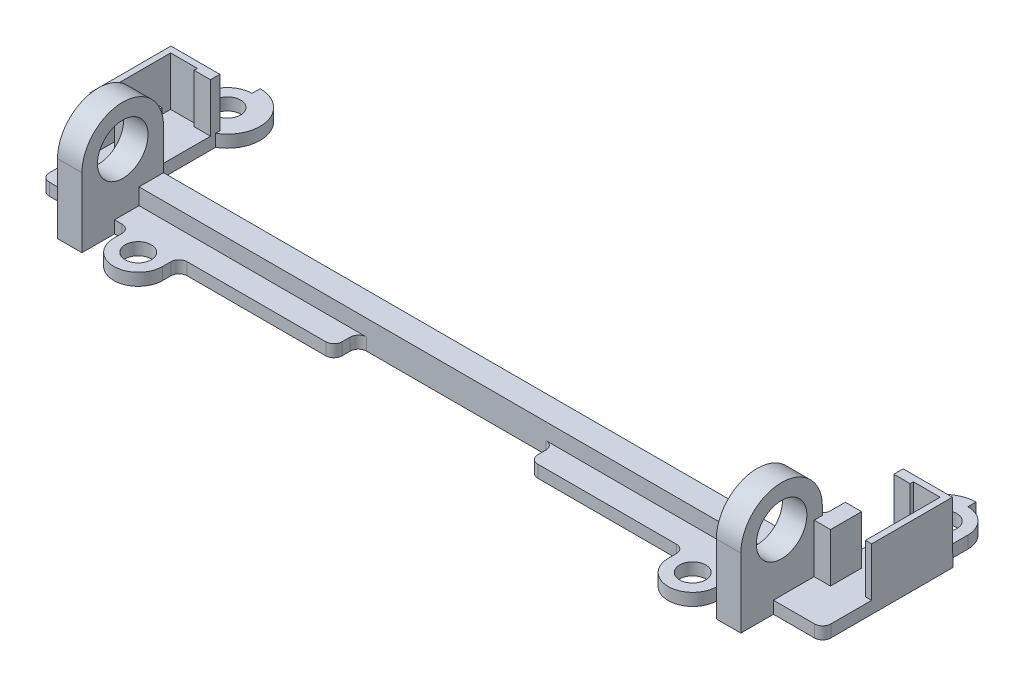
from build123d import *

# Parameters (mm, degrees)
BOSS_EXTRUDE1_START      = -0.5
BOSS_EXTRUDE1_DEPTH      = 1.5
SKETCH2_R                = 1.6
CUT_EXTRUDE1_DEPTH       = 1
SKETCH3_W                = 0.75
SKETCH3_H                = 10
BOSS_EXTRUDE2_DEPTH      = 5
BOSS_EXTRUDE3_DEPTH      = 5
SKETCH5_W                = 4.286948095
SKETCH5_H                = 10
SKETCH5_W_2              = 4.25
CUT_EXTRUDE2_DEPTH       = 51
SKETCH6_R                = 1.6
BOSS_EXTRUDE4_DEPTH      = 1.5
CUT_EXTRUDE3_DEPTH       = 51
SKETCH9_W                = 1.486095819
SKETCH9_H                = 8.860387047
BOSS_EXTRUDE5_DEPTH      = 1.5
SKETCH10_W               = 0.325570639
SKETCH10_H               = 19.562658846
CUT_EXTRUDE4_DEPTH       = 51
SKETCH11_W               = 2.963051905
SKETCH11_H               = 0.75
BOSS_EXTRUDE6_DEPTH      = 5
CUT_EXTRUDE5_DEPTH       = 24
CUT_EXTRUDE5_DEPTH_BACK  = 10
SKETCH13_W               = 3.75
SKETCH13_H               = 0.877509659
BOSS_EXTRUDE7_DEPTH      = 5
CUT_EXTRUDE8_DEPTH       = 24
CUT_EXTRUDE9_DEPTH       = 24
SKETCH17_W               = 0.75
SKETCH17_H               = 6
CUT_EXTRUDE10_DEPTH      = 5
SKETCH18_R               = 23.563535961
CUT_EXTRUDE11_DEPTH      = 50
SKETCH19_W               = 0.75
SKETCH19_H               = 3.122490341
SKETCH19_W_2             = 3.75
SKETCH19_H_2             = 0.877509659
BOSS_EXTRUDE8_DEPTH      = 5
BOSS_EXTRUDE9_DEPTH      = 1.5
SKETCH21_R               = 54.234395916
CUT_EXTRUDE12_DEPTH      = 26
BOSS_EXTRUDE10_DEPTH     = 1.5
BOSS_EXTRUDE11_DEPTH     = 1.5
SKETCH24_W               = 6.036948095
SKETCH24_H               = 1
SKETCH24_W_2             = 6
SKETCH24_W_3             = 2
SKETCH24_H_2             = 2.410061644
BOSS_EXTRUDE13_DEPTH     = 6
SKETCH25_W               = 2.5
SKETCH25_H               = 0.4
BOSS_EXTRUDE14_DEPTH     = 6
SKETCH26_W               = 0.75
SKETCH26_H               = 8.410061644
BOSS_EXTRUDE15_DEPTH     = 6
SKETCH27_W               = 0.5
SKETCH27_H               = 8.410061644
CUT_EXTRUDE13_DEPTH      = 6
SKETCH28_W               = 3
SKETCH28_H               = 4
BOSS_EXTRUDE18_DEPTH     = 13
SKETCH29_R               = 3.1
CUT_EXTRUDE14_DEPTH      = 154
CUT_EXTRUDE14_DEPTH_BACK = 13
SKETCH30_W               = 2
SKETCH30_H               = 5.827825404
CUT_EXTRUDE15_DEPTH      = 20
SKETCH31_W               = 8
SKETCH31_H               = 3
CUT_EXTRUDE16_DEPTH      = 20
SKETCH32_R               = 1.6
BOSS_EXTRUDE19_DEPTH     = 1.5
SKETCH34_W               = 3
SKETCH34_H               = 4
BOSS_EXTRUDE20_DEPTH     = 1.5
SKETCH35_W               = 4
SKETCH35_H               = 3
CUT_EXTRUDE17_DEPTH      = 1.5
FILLET2_R                = 1
BOSS_EXTRUDE21_DEPTH     = 2
SKETCH37_W               = 6
SKETCH37_H               = 0.5
BOSS_EXTRUDE22_DEPTH     = 6
SKETCH38_W               = 0.036948095
SKETCH38_H               = 0.5
BOSS_EXTRUDE23_DEPTH     = 6
SKETCH39_W               = 0.036948095
SKETCH39_H               = 8.410061644
CUT_EXTRUDE18_DEPTH      = 14
CUT_EXTRUDE19_DEPTH      = 6
SKETCH41_W               = 2
SKETCH41_H               = 0.4
BOSS_EXTRUDE25_DEPTH     = 6
CUT_EXTRUDE20_DEPTH      = 6
SKETCH43_W               = 2
SKETCH43_H               = 0.4
BOSS_EXTRUDE26_DEPTH     = 6
SKETCH44_R               = 3.1
BOSS_EXTRUDE27_DEPTH     = 3
SKETCH45_R               = 1.6
CUT_EXTRUDE21_DEPTH      = 8
CUT_EXTRUDE21_DEPTH_BACK = 155
SKETCH46_R               = 3.1
BOSS_EXTRUDE28_DEPTH     = 3
SKETCH47_R               = 3.1
CUT_EXTRUDE22_DEPTH      = 155
SKETCH49_R               = 4
BOSS_EXTRUDE29_DEPTH     = 1.5
SKETCH50_R               = 1.6
CUT_EXTRUDE23_DEPTH      = 10
CUT_EXTRUDE25_DEPTH      = 3.5


with BuildPart() as part:
    # Sketch1 → Boss-Extrude1 (new body)
    with BuildSketch(Plane(origin=(0, 0, 0), x_dir=(1, 0, 0), z_dir=(0, 1, 0)).offset(BOSS_EXTRUDE1_START)):
        Polygon((0, 0), (39.901051905, 0), (39.901051905, 10), (43.938, 10), (47.938, 10), (47.938, -6), (-47.938, -6), (-47.938, 10), (-43.938, 10), (-39.938, 10), (-39.938, 0), align=None)
    boss_extrude1 = extrude(amount=BOSS_EXTRUDE1_DEPTH)

    # Sketch2 → Cut-Extrude1 (cut)
    with BuildSketch(Plane(origin=(0, 1, 0), x_dir=(1, 0, 0), z_dir=(0, 1, 0))):
        with Locations(Location((-43.938, 2.852566903, 0), (0, 0, 270))):
            Circle(SKETCH2_R)
        with Locations(Location((43.921766654, 2.513393114, 0), (0, 0, 90))):
            Circle(SKETCH2_R)
    extrude(amount=-CUT_EXTRUDE1_DEPTH, mode=Mode.SUBTRACT)

    # Sketch3 → Boss-Extrude2 (add)
    with BuildSketch(Plane(origin=(0, 1, 0), x_dir=(1, 0, 0), z_dir=(0, 1, 0))):
        with Locations((-40.313, 5)):
            Rectangle(SKETCH3_W, SKETCH3_H)
        with Locations((40.276051905, 5)):
            Rectangle(SKETCH3_W, SKETCH3_H)
    extrude(amount=BOSS_EXTRUDE2_DEPTH)

    # Sketch4 → Boss-Extrude3 (add)
    with BuildSketch(Plane(origin=(0, 1, 0), x_dir=(1, 0, 0), z_dir=(0, 1, 0))):
        with BuildLine():
            Line((-44.188, 4.432914966), (-44.188, 10))
            Line((-44.188, 10), (-44.938, 10))
            Line((-44.938, 10), (-44.938, 4.101566503))
            ThreePointArc((-44.938, 4.101566503), (-44.58458561, 4.31609929), (-44.188, 4.432914966))
        make_face()
        with BuildLine():
            Line((-44.188, 1.27221884), (-44.188, 4.432914966))
            ThreePointArc((-44.188, 4.432914966), (-44.58458561, 4.31609929), (-44.938, 4.101566503))
            Line((-44.938, 4.101566503), (-44.938, 1.603567303))
            ThreePointArc((-44.938, 1.603567303), (-44.58458561, 1.389034515), (-44.188, 1.27221884))
        make_face()
        with BuildLine():
            Line((-44.188, 0), (-44.188, 1.27221884))
            ThreePointArc((-44.188, 1.27221884), (-44.58458561, 1.389034515), (-44.938, 1.603567303))
            Line((-44.938, 1.603567303), (-44.938, 0))
            Line((-44.938, 0), (-44.188, 0))
        make_face()
        with BuildLine():
            Line((44.938, 3.749220685), (44.938, 10))
            Line((44.938, 10), (44.188, 10))
            Line((44.188, 10), (44.188, 4.091087572))
            ThreePointArc((44.188, 4.091087572), (44.585391884, 3.969278258), (44.938, 3.749220685))
        make_face()
        with BuildLine():
            Line((44.938, 1.277565542), (44.938, 3.749220685))
            ThreePointArc((44.938, 3.749220685), (44.585391884, 3.969278258), (44.188, 4.091087572))
            Line((44.188, 4.091087572), (44.188, 0.935698655))
            ThreePointArc((44.188, 0.935698655), (44.585391884, 1.057507969), (44.938, 1.277565542))
        make_face()
        with BuildLine():
            Line((44.938, 0), (44.938, 1.277565542))
            ThreePointArc((44.938, 1.277565542), (44.585391884, 1.057507969), (44.188, 0.935698655))
            Line((44.188, 0.935698655), (44.188, 0))
            Line((44.188, 0), (44.938, 0))
        make_face()
    boss_extrude3 = extrude(amount=BOSS_EXTRUDE3_DEPTH)

    # Sketch5 → Cut-Extrude2 (cut)
    with BuildSketch(Plane(origin=(0, 1, 0), x_dir=(1, 0, 0), z_dir=(0, 1, 0))):
        with Locations((42.044525953, 5)):
            Rectangle(SKETCH5_W, SKETCH5_H)
        with Locations((-42.063, 5)):
            Rectangle(SKETCH5_W_2, SKETCH5_H)
    extrude(amount=CUT_EXTRUDE2_DEPTH, mode=Mode.SUBTRACT)

    # Sketch6 → Boss-Extrude4 (add)
    with BuildSketch(Plane(origin=(0, 1, 0), x_dir=(1, 0, 0), z_dir=(0, 1, 0))):
        with BuildLine():
            Line((-47.938, 12.852566903), (-47.938, 10))
            Line((-47.938, 10), (-44.938, 10))
            Line((-44.938, 10), (-44.188, 10))
            Line((-44.188, 10), (-39.938, 10))
            Line((-39.938, 10), (-39.938, 12.852566903))
            ThreePointArc((-39.938, 12.852566903), (-43.938, 16.852566903), (-47.938, 12.852566903))
        make_face()
        with Locations(Location((-43.938, 12.852566903, 0), (0, 0, 270))):
            Circle(SKETCH6_R, mode=Mode.SUBTRACT)
        with BuildLine():
            Line((44.938, 10), (47.901051905, 10))
            Line((47.901051905, 10), (47.901051905, 12.852566903))
            ThreePointArc((47.901051905, 12.852566903), (43.901051905, 16.852566903), (39.901051905, 12.852566903))
            Line((39.901051905, 12.852566903), (39.901051905, 10))
            Line((39.901051905, 10), (44.188, 10))
            Line((44.188, 10), (44.938, 10))
        make_face()
        with Locations(Location((43.901051905, 12.852566903, 0), (0, 0, 270))):
            Circle(SKETCH6_R, mode=Mode.SUBTRACT)
        with BuildLine():
            ThreePointArc((-44.188, 4.432914966), (-42.338, 2.852566903), (-44.188, 1.27221884))
            Line((-44.188, 1.27221884), (-44.188, 0))
            Line((-44.188, 0), (-44.938, 0))
            Line((-44.938, 0), (-44.938, 1.603567303))
            ThreePointArc((-44.938, 1.603567303), (-45.538, 2.852566903), (-44.938, 4.101566503))
            Line((-44.938, 4.101566503), (-44.938, 10))
            Line((-44.938, 10), (-47.938, 10))
            Line((-47.938, 10), (-47.938, -6))
            Line((-47.938, -6), (47.938, -6))
            Line((47.938, -6), (47.938, 10))
            Line((47.938, 10), (44.938, 10))
            Line((44.938, 10), (44.938, 3.749220685))
            ThreePointArc((44.938, 3.749220685), (45.521766654, 2.513393114), (44.938, 1.277565542))
            Line((44.938, 1.277565542), (44.938, 0))
            Line((44.938, 0), (44.188, 0))
            Line((44.188, 0), (44.188, 0.935698655))
            ThreePointArc((44.188, 0.935698655), (42.321766654, 2.513393114), (44.188, 4.091087572))
            Line((44.188, 4.091087572), (44.188, 10))
            Line((44.188, 10), (39.901051905, 10))
            Line((39.901051905, 10), (39.901051905, 0))
            Line((39.901051905, 0), (-39.938, 0))
            Line((-39.938, 0), (-39.938, 10))
            Line((-39.938, 10), (-44.188, 10))
            Line((-44.188, 10), (-44.188, 4.432914966))
        make_face()
    boss_extrude4 = extrude(amount=-BOSS_EXTRUDE4_DEPTH)

    # Sketch8 → Cut-Extrude3 (cut)
    with BuildSketch(Plane(origin=(0, -0.5, 0), x_dir=(-1, 0, 0), z_dir=(0, -1, 0))):
        with BuildLine():
            Line((44.188, 2.852566903), (44.188, 8.860387047))
            ThreePointArc((44.188, 8.860387047), (41.199387212, 9.937090955), (39.938, 12.852566903))
            Line((39.938, 12.852566903), (39.938, 0))
            Line((39.938, 0), (44.188, 0))
            Line((44.188, 0), (44.188, 2.852566903))
        make_face()
        with BuildLine():
            Line((-39.901051905, 0), (-39.901051905, 12.852566903))
            ThreePointArc((-39.901051905, 12.852566903), (-41.162439117, 9.937090955), (-44.151051905, 8.860387047))
            Line((-44.151051905, 8.860387047), (-44.151051905, 2.852566903))
            Line((-44.151051905, 2.852566903), (-44.151051905, 0))
            Line((-44.151051905, 0), (-39.901051905, 0))
        make_face()
    extrude(amount=-CUT_EXTRUDE3_DEPTH, mode=Mode.SUBTRACT)

    # Sketch9 → Boss-Extrude5 (add)
    with BuildSketch(Plane(origin=(0, -0.5, 0), x_dir=(-1, 0, 0), z_dir=(0, -1, 0))):
        with Locations((44.93104791, 4.430193523)):
            Rectangle(SKETCH9_W, SKETCH9_H)
        with Locations((-44.894099815, 4.430193523)):
            Rectangle(SKETCH9_W, SKETCH9_H)
    extrude(amount=-BOSS_EXTRUDE5_DEPTH)

    # Sketch10 → Cut-Extrude4 (cut)
    with BuildSketch(Plane(origin=(0, 1, 0), x_dir=(1, 0, 0), z_dir=(0, 1, 0))):
        with Locations((48.063837225, 3.07123748)):
            Rectangle(SKETCH10_W, SKETCH10_H)
    extrude(amount=-CUT_EXTRUDE4_DEPTH, mode=Mode.SUBTRACT)

    # Sketch11 → Boss-Extrude6 (add)
    with BuildSketch(Plane(origin=(0, 1, 0), x_dir=(1, 0, 0), z_dir=(0, 1, 0))):
        with Locations((46.419525953, 9.625)):
            Rectangle(SKETCH11_W, SKETCH11_H)
        with Locations((-46.419525953, 9.625)):
            Rectangle(SKETCH11_W, SKETCH11_H)
    extrude(amount=BOSS_EXTRUDE6_DEPTH)

    # Sketch12 → Cut-Extrude5 (cut, two sides)
    with BuildSketch(Plane(origin=(0, 1, 0), x_dir=(1, 0, 0), z_dir=(0, 1, 0))) as cut_extrude5_sk:
        with BuildLine():
            Line((44.151051905, 0), (0, 0))
            Line((0, 0), (0, -6))
            Line((0, -6), (47.901051905, -6))
            Line((47.901051905, -6), (47.901051905, 9.25))
            Line((47.901051905, 9.25), (44.938, 9.25))
            Line((44.938, 9.25), (44.938, 0))
            Line((44.938, 0), (44.188, 0))
            Line((44.188, 0), (44.188, 10))
            Line((44.188, 10), (47.901051905, 10))
            Line((47.901051905, 10), (47.901051905, 12.852566903))
            ThreePointArc((47.901051905, 12.852566903), (43.901051905, 16.852566903), (39.901051905, 12.852566903))
            ThreePointArc((39.901051905, 12.852566903), (41.162439117, 9.937090955), (44.151051905, 8.860387047))
            Line((44.151051905, 8.860387047), (44.151051905, 0))
        make_face()
        with BuildLine():
            ThreePointArc((45.501051905, 12.852566903), (43.901051905, 11.252566903), (42.301051905, 12.852566903))
            ThreePointArc((42.301051905, 12.852566903), (43.901051905, 14.452566903), (45.501051905, 12.852566903))
        make_face(mode=Mode.SUBTRACT)
    extrude(amount=CUT_EXTRUDE5_DEPTH, mode=Mode.SUBTRACT)
    extrude(cut_extrude5_sk.sketch, amount=-CUT_EXTRUDE5_DEPTH_BACK, mode=Mode.SUBTRACT)


with BuildPart() as cut_extrude5_kept_piece:
    # of the separate pieces the step leaves, the one the design keeps (cut_extrude5_pieces_kept)
    add(part.part.solids().sort_by_distance((0, -0.5, 0))[0])

    # Mirror1: Boss-Extrude1, Boss-Extrude3, Boss-Extrude4 across plane
    add(boss_extrude1.mirror(Plane(origin=(0, -9, 0), x_dir=(0, 0, 1), z_dir=(1, 0, 0))))
    add(boss_extrude3.mirror(Plane(origin=(0, -9, 0), x_dir=(0, 0, 1), z_dir=(1, 0, 0))))
    add(boss_extrude4.mirror(Plane(origin=(0, -9, 0), x_dir=(0, 0, 1), z_dir=(1, 0, 0))))

    # Sketch13 → Boss-Extrude7 (add)
    with BuildSketch(Plane(origin=(0, 1, 0), x_dir=(1, 0, 0), z_dir=(0, 1, 0))):
        with Locations((46.063, 9.561245171)):
            Rectangle(SKETCH13_W, SKETCH13_H)
    extrude(amount=BOSS_EXTRUDE7_DEPTH)

    # Sketch14 → Cut-Extrude8 (cut)
    with BuildSketch(Plane(origin=(0, 1, 0), x_dir=(1, 0, 0), z_dir=(0, 1, 0))):
        with BuildLine():
            Line((44.188, 8.860387047), (44.188, 0))
            Line((44.188, 0), (39.938, 0))
            Line((39.938, 0), (39.938, 12.852566903))
            ThreePointArc((39.938, 12.852566903), (41.199387212, 9.937090955), (44.188, 8.860387047))
        make_face()
        with BuildLine():
            Line((-39.938, 0), (-39.938, 12.852566903))
            ThreePointArc((-39.938, 12.852566903), (-41.199387212, 9.937090955), (-44.188, 8.860387047))
            Line((-44.188, 8.860387047), (-44.188, 0))
            Line((-44.188, 0), (-39.938, 0))
        make_face()
    extrude(amount=-CUT_EXTRUDE8_DEPTH, mode=Mode.SUBTRACT)

    # Sketch16 → Cut-Extrude9 (cut)
    with BuildSketch(Plane(origin=(0, 1, 0), x_dir=(1, 0, 0), z_dir=(0, 1, 0))):
        with BuildLine():
            Line((-47.901051905, 12.852566903), (-47.901051905, -8.737912396))
            Line((-47.901051905, -8.737912396), (-59.17463004, -3.945157427))
            Line((-59.17463004, -3.945157427), (-50.594052594, 27.053144877))
            Line((-50.594052594, 27.053144877), (-22.185384024, 22.801507404))
            Line((-22.185384024, 22.801507404), (-38.341606422, 0))
            Line((-38.341606422, 0), (-41.70426515, 0))
            Line((-41.70426515, 0), (-41.70426515, 9.509794408))
            ThreePointArc((-41.70426515, 9.509794408), (-42.001992535, 16.373017657), (-47.901051905, 12.852566903))
        make_face()
    extrude(amount=-CUT_EXTRUDE9_DEPTH, mode=Mode.SUBTRACT)

    # Sketch17 → Cut-Extrude10 (cut)
    with BuildSketch(Plane(origin=(0, 6, 0), x_dir=(1, 0, 0), z_dir=(0, 1, 0))):
        with Locations((44.563, 6.122490341)):
            Rectangle(SKETCH17_W, SKETCH17_H)
        with Locations((-44.563, 6.122490341)):
            Rectangle(SKETCH17_W, SKETCH17_H)
    extrude(amount=-CUT_EXTRUDE10_DEPTH, mode=Mode.SUBTRACT)

    # Sketch18 → Cut-Extrude11 (cut)
    with BuildSketch(Plane(origin=(0, 1, 0), x_dir=(1, 0, 0), z_dir=(0, 1, 0))):
        with Locations((-44.188, 8.860387047)):
            Circle(SKETCH18_R)
    extrude(amount=CUT_EXTRUDE11_DEPTH, mode=Mode.SUBTRACT)

    # Sketch19 → Boss-Extrude8 (add)
    with BuildSketch(Plane(origin=(0, 1, 0), x_dir=(1, 0, 0), z_dir=(0, 1, 0))):
        Polygon((-47.901051905, 9.122490341), (-44.938, 9.122490341), (-44.188, 9.122490341), (-44.188, 10), (-47.901051905, 10), align=None)
        Polygon((-44.938, 8.434081652), (-44.188, 8.434081652), (-44.188, 8.860387047), (-44.188, 9.122490341), (-44.938, 9.122490341), align=None)
        with Locations((-44.563, 1.561245171)):
            Rectangle(SKETCH19_W, SKETCH19_H)
        with Locations((46.063, 9.561245171)):
            Rectangle(SKETCH19_W_2, SKETCH19_H_2)
        Polygon((44.938, 9.122490341), (44.188, 9.122490341), (44.188, 8.860387047), (44.188, 8.434081652), (44.938, 8.434081652), align=None)
    extrude(amount=BOSS_EXTRUDE8_DEPTH)

    # Sketch20 → Boss-Extrude9 (add)
    with BuildSketch(Plane(origin=(0, 1, 0), x_dir=(1, 0, 0), z_dir=(0, 1, 0))):
        Polygon((43.938, 8.852566903), (43.938, 0), (44.188, 0), (44.188, 8.860387047), align=None)
        Polygon((-44.188, 8.860387047), (-43.938, 8.852566903), (-43.938, 0), (-44.188, 0), align=None)
    extrude(amount=-BOSS_EXTRUDE9_DEPTH)

    # Sketch21 → Cut-Extrude12 (cut)
    with BuildSketch(Plane(origin=(0, 1, 0), x_dir=(1, 0, 0), z_dir=(0, 1, 0))):
        Circle(SKETCH21_R)
    extrude(amount=CUT_EXTRUDE12_DEPTH, mode=Mode.SUBTRACT)

    # Sketch22 → Boss-Extrude10 (add)
    with BuildSketch(Plane(origin=(0, 1, 0), x_dir=(1, 0, 0), z_dir=(0, 1, 0))):
        Polygon((-42.901051905, 3.426283451), (-42.901051905, 0), (-43.938, 0), (-43.938, 8.852566903), (-42.901051905, 9.79950521), align=None)
        Polygon((42.901051905, 9.79950521), (43.938, 8.852566903), (43.938, 0), (42.901051905, 0), (42.901051905, 3.426283451), align=None)
    extrude(amount=-BOSS_EXTRUDE10_DEPTH)

    # Sketch23 → Boss-Extrude11 (add)
    with BuildSketch(Plane(origin=(0, 1, 0), x_dir=(1, 0, 0), z_dir=(0, 1, 0))):
        Polygon((-42.901051905, 0), (-41.901051905, 0), (-41.901051905, 10.289022351), (-42.901051905, 8.989311974), align=None)
        Polygon((42.901051905, 8.989311974), (42.901051905, 0), (41.901051905, 0), (41.901051905, 10.289022351), align=None)
    extrude(amount=-BOSS_EXTRUDE11_DEPTH)

    # Sketch24 → Boss-Extrude13 (add)
    with BuildSketch(Plane(origin=(0, 1, 0), x_dir=(1, 0, 0), z_dir=(0, 1, 0))):
        with Locations((44.919525953, 8.910061644)):
            Rectangle(SKETCH24_W, SKETCH24_H)
        with Locations((-44.901051905, 8.910061644)):
            Rectangle(SKETCH24_W_2, SKETCH24_H)
        with Locations((-42.901051905, 1.205030822)):
            Rectangle(SKETCH24_W_3, SKETCH24_H_2)
        with Locations((42.901051905, 1.205030822)):
            Rectangle(SKETCH24_W_3, SKETCH24_H_2)
    extrude(amount=BOSS_EXTRUDE13_DEPTH)

    # Sketch25 → Boss-Extrude14 (add)
    with BuildSketch(Plane(origin=(0, 1, 0), x_dir=(1, 0, 0), z_dir=(0, 1, 0))):
        with Locations((-43.151051905, 8.210061644)):
            Rectangle(SKETCH25_W, SKETCH25_H)
        Polygon((-41.901051905, 2.410061644), (-41.901051905, 2.810061644), (-44.401051905, 2.810061644), (-44.401051905, 0), (-41.901051905, 0), align=None)
        Polygon((41.901051905, 0), (41.901051905, 2.410061644), (41.901051905, 2.810061644), (44.401051905, 2.810061644), (44.401051905, 0), align=None)
        with Locations((43.151051905, 8.210061644)):
            Rectangle(SKETCH25_W, SKETCH25_H)
    extrude(amount=BOSS_EXTRUDE14_DEPTH)

    # Sketch26 → Boss-Extrude15 (add)
    with BuildSketch(Plane(origin=(0, 1, 0), x_dir=(1, 0, 0), z_dir=(0, 1, 0))):
        with Locations((47.563, 4.205030822)):
            Rectangle(SKETCH26_W, SKETCH26_H)
        with Locations((-47.563, 4.205030822)):
            Rectangle(SKETCH26_W, SKETCH26_H)
    extrude(amount=BOSS_EXTRUDE15_DEPTH)

    # Sketch27 → Cut-Extrude13 (cut)
    with BuildSketch(Plane(origin=(0, 7, 0), x_dir=(1, 0, 0), z_dir=(0, 1, 0))):
        with Locations((44.151051905, 4.205030822)):
            Rectangle(SKETCH27_W, SKETCH27_H)
        with Locations((-44.151051905, 4.205030822)):
            Rectangle(SKETCH27_W, SKETCH27_H)
    extrude(amount=-CUT_EXTRUDE13_DEPTH, mode=Mode.SUBTRACT)

    # Sketch28 → Boss-Extrude18 (add)
    with BuildSketch(Plane(origin=(0, 1, 0), x_dir=(1, 0, 0), z_dir=(0, 1, 0))):
        Polygon((-38.901051905, -6), (-38.901051905, 0), (-41.901051905, 0), (-43.901051905, 0), (-43.901051905, -1), (-41.901051905, -1), (-41.901051905, -6), align=None)
        with Locations((-40.401051905, -8)):
            Rectangle(SKETCH28_W, SKETCH28_H)
        Polygon((43.901051905, 0), (41.901051905, 0), (38.901051905, 0), (38.901051905, -6), (41.901051905, -6), (41.901051905, -1), (43.901051905, -1), align=None)
        with Locations((40.401051905, -8)):
            Rectangle(SKETCH28_W, SKETCH28_H)
    extrude(amount=BOSS_EXTRUDE18_DEPTH)

    # Sketch29 → Cut-Extrude14 (cut, two sides)
    with BuildSketch(Plane(origin=(-38.901051905, 0, 0), x_dir=(0, 0, -1), z_dir=(1, 0, 0))) as cut_extrude14_sk:
        with Locations(Location((-5, 9, 0), (0, 0, 180))):
            Circle(SKETCH29_R)
        with BuildLine():
            Line((0, 14), (-5, 14))
            ThreePointArc((-5, 14), (-1.464466094, 12.535533906), (0, 9))
            Line((0, 9), (0, 14))
        make_face()
        with BuildLine():
            ThreePointArc((-10, 9), (-8.535533906, 12.535533906), (-5, 14))
            Line((-5, 14), (-10, 14))
            Line((-10, 14), (-10, 9))
        make_face()
    extrude(amount=CUT_EXTRUDE14_DEPTH, mode=Mode.SUBTRACT)
    extrude(cut_extrude14_sk.sketch, amount=-CUT_EXTRUDE14_DEPTH_BACK, mode=Mode.SUBTRACT)

    # Sketch30 → Cut-Extrude15 (cut)
    with BuildSketch(Plane(origin=(0, 7, 0), x_dir=(1, 0, 0), z_dir=(0, 1, 0))):
        with Locations((-42.901051905, -0.103851058)):
            Rectangle(SKETCH30_W, SKETCH30_H)
        with Locations((42.901051905, -0.103851058)):
            Rectangle(SKETCH30_W, SKETCH30_H)
    extrude(amount=CUT_EXTRUDE15_DEPTH, mode=Mode.SUBTRACT)

    # Sketch31 → Cut-Extrude16 (cut)
    with BuildSketch(Plane(origin=(0, 1, 0), x_dir=(1, 0, 0), z_dir=(0, 1, 0))):
        with Locations((4, -4.5)):
            Rectangle(SKETCH31_W, SKETCH31_H)
        with Locations((-4, -4.5)):
            Rectangle(SKETCH31_W, SKETCH31_H)
    extrude(amount=-CUT_EXTRUDE16_DEPTH, mode=Mode.SUBTRACT)

    # Sketch32 → Boss-Extrude19 (add)
    with BuildSketch(Plane(origin=(0, 1, 0), x_dir=(1, 0, 0), z_dir=(0, 1, 0))):
        with BuildLine():
            Line((-31, -8), (-31, -6))
            Line((-31, -6), (-37, -6))
            Line((-37, -6), (-37, -8))
            ThreePointArc((-37, -8), (-34, -11), (-31, -8))
        make_face()
        with Locations(Location((-34, -8, 0), (0, 0, 270))):
            Circle(SKETCH32_R, mode=Mode.SUBTRACT)
        with BuildLine():
            Line((37, -6), (31, -6))
            Line((31, -6), (31, -8))
            ThreePointArc((31, -8), (34, -11), (37, -8))
            Line((37, -8), (37, -6))
        make_face()
        with Locations(Location((34, -8, 0), (0, 0, 270))):
            Circle(SKETCH32_R, mode=Mode.SUBTRACT)
    extrude(amount=-BOSS_EXTRUDE19_DEPTH)

    # Sketch34 → Boss-Extrude20 (add)
    with BuildSketch(Plane(origin=(0, 1, 0), x_dir=(-1, 0, 0), z_dir=(0, -1, 0))):
        with Locations((40.401051905, -8)):
            Rectangle(SKETCH34_W, SKETCH34_H)
        with Locations((-40.401051905, -8)):
            Rectangle(SKETCH34_W, SKETCH34_H)
    extrude(amount=BOSS_EXTRUDE20_DEPTH)

    # Sketch35 → Cut-Extrude17 (cut)
    with BuildSketch(Plane(origin=(0, 1, 0), x_dir=(1, 0, 0), z_dir=(0, 1, 0))):
        with Locations((10, -4.5)):
            Rectangle(SKETCH35_W, SKETCH35_H)
        with Locations((-10, -4.5)):
            Rectangle(SKETCH35_W, SKETCH35_H)
    extrude(amount=-CUT_EXTRUDE17_DEPTH, mode=Mode.SUBTRACT)

    # Fillet2
    fillet2_edges = [cut_extrude5_kept_piece.edges().sort_by_distance(p)[0] for p in [
        (-31, 0.25, 6),
        (-37, 0.25, 6),
        (37, 0.25, 6),
        (31, 0.25, 6),
        (12, 0.25, 3),
        (12, 0.25, 6),
        (-12, 0.25, 6),
        (-12, 0.25, 3),
        (47.938, 0.25, 6),
        (-47.901051905, 0.25, 6),
        (-41.901051905, 3.25, 0),
        (41.901051905, 3.25, 0),
    ]]
    fillet(fillet2_edges, radius=FILLET2_R)

    # Sketch36 → Boss-Extrude21 (add)
    with BuildSketch(Plane(origin=(0, 1, 0), x_dir=(1, 0, 0), z_dir=(0, 1, 0))):
        Polygon((0, -3), (38.901051905, -3), (38.901051905, 0), (-38.901051905, 0), (-38.901051905, -3), align=None)
    extrude(amount=BOSS_EXTRUDE21_DEPTH)

    # Sketch37 → Boss-Extrude22 (add)
    with BuildSketch(Plane(origin=(0, 1, 0), x_dir=(1, 0, 0), z_dir=(0, 1, 0))):
        with Locations((-44.901051905, 9.660061644)):
            Rectangle(SKETCH37_W, SKETCH37_H)
        with Locations((44.901051905, 9.660061644)):
            Rectangle(SKETCH37_W, SKETCH37_H)
    extrude(amount=BOSS_EXTRUDE22_DEPTH)

    # Sketch38 → Boss-Extrude23 (add)
    with BuildSketch(Plane(origin=(0, 1, 0), x_dir=(1, 0, 0), z_dir=(0, 1, 0))):
        with Locations((47.919525953, 9.660061644)):
            Rectangle(SKETCH38_W, SKETCH38_H)
    extrude(amount=BOSS_EXTRUDE23_DEPTH)

    # Sketch39 → Cut-Extrude18 (cut)
    with BuildSketch(Plane(origin=(0, 7, 0), x_dir=(1, 0, 0), z_dir=(0, 1, 0))):
        with Locations((-47.919525953, 4.205030822)):
            Rectangle(SKETCH39_W, SKETCH39_H)
    extrude(amount=-CUT_EXTRUDE18_DEPTH, mode=Mode.SUBTRACT)

    # Sketch40 → Cut-Extrude19 (cut)
    with BuildSketch(Plane(origin=(0, 7, 0), x_dir=(1, 0, 0), z_dir=(0, 1, 0))):
        Polygon((-47.188, 8.410061644), (-47.188, 9.160061644), (-41.901051905, 9.160061644), (-41.901051905, 8.010061644), (-47.188, 8.010061644), align=None)
    extrude(amount=-CUT_EXTRUDE19_DEPTH, mode=Mode.SUBTRACT)

    # Sketch41 → Boss-Extrude25 (add)
    with BuildSketch(Plane(origin=(0, 1, 0), x_dir=(1, 0, 0), z_dir=(0, 1, 0))):
        with Locations((-42.901051905, 8.960061644)):
            Rectangle(SKETCH41_W, SKETCH41_H)
    extrude(amount=BOSS_EXTRUDE25_DEPTH)

    # Sketch42 → Cut-Extrude20 (cut)
    with BuildSketch(Plane(origin=(0, 7, 0), x_dir=(1, 0, 0), z_dir=(0, 1, 0))):
        Polygon((47.188, 8.410061644), (47.188, 9.160061644), (41.901051905, 9.160061644), (41.901051905, 8.010061644), (47.188, 8.010061644), align=None)
    extrude(amount=-CUT_EXTRUDE20_DEPTH, mode=Mode.SUBTRACT)

    # Sketch43 → Boss-Extrude26 (add)
    with BuildSketch(Plane(origin=(0, 1, 0), x_dir=(1, 0, 0), z_dir=(0, 1, 0))):
        with Locations((42.901051905, 8.960061644)):
            Rectangle(SKETCH43_W, SKETCH43_H)
    extrude(amount=BOSS_EXTRUDE26_DEPTH)

    # Sketch44 → Boss-Extrude27 (add)
    with BuildSketch(Plane(origin=(41.901051905, 0, 0), x_dir=(0, 0, -1), z_dir=(1, 0, 0))):
        with Locations(Location((-5, 9, 0), (0, 0, 180))):
            Circle(SKETCH44_R)
    extrude(amount=-BOSS_EXTRUDE27_DEPTH)

    # Sketch45 → Cut-Extrude21 (cut, two sides)
    with BuildSketch(Plane(origin=(41.901051905, 0, 0), x_dir=(0, 0, -1), z_dir=(1, 0, 0))) as cut_extrude21_sk:
        with Locations(Location((-5, 8, 0), (0, 0, 180))):
            Circle(SKETCH45_R)
        with BuildLine():
            ThreePointArc((0, 9), (-1.464466094, 12.535533906), (-5, 14))
            Line((-5, 14), (-5, 13))
            ThreePointArc((-5, 13), (-1.464466094, 11.535533906), (0, 8))
            Line((0, 8), (0, 9))
        make_face()
        with BuildLine():
            Line((-5, 13), (-5, 14))
            ThreePointArc((-5, 14), (-8.535533906, 12.535533906), (-10, 9))
            Line((-10, 9), (-10, 8))
            ThreePointArc((-10, 8), (-8.535533906, 11.535533906), (-5, 13))
        make_face()
    extrude(amount=CUT_EXTRUDE21_DEPTH, mode=Mode.SUBTRACT)
    extrude(cut_extrude21_sk.sketch, amount=-CUT_EXTRUDE21_DEPTH_BACK, mode=Mode.SUBTRACT)

    # Sketch46 → Boss-Extrude28 (add)
    with BuildSketch(Plane.ZY.offset(41.901051905)):
        with Locations((5, 9)):
            Circle(SKETCH46_R)
    extrude(amount=-BOSS_EXTRUDE28_DEPTH)

    # Sketch47 → Cut-Extrude22 (cut)
    with BuildSketch(Plane.ZY.offset(41.901051905)):
        with Locations((5, 8)):
            Circle(SKETCH47_R)
    extrude(amount=-CUT_EXTRUDE22_DEPTH, mode=Mode.SUBTRACT)

    # Sketch49 → Boss-Extrude29 (add)
    with BuildSketch(Plane(origin=(0, -0.5, 0), x_dir=(-1, 0, 0), z_dir=(0, -1, 0))):
        with Locations((43.901051905, 12.852566903)):
            Circle(SKETCH49_R)
    extrude(amount=-BOSS_EXTRUDE29_DEPTH)

    # Sketch50 → Cut-Extrude23 (cut)
    with BuildSketch(Plane(origin=(0, 1, 0), x_dir=(1, 0, 0), z_dir=(0, 1, 0))):
        with Locations(Location((-43.901051905, 12.852566903, 0), (0, 0, 270))):
            Circle(SKETCH50_R)
    extrude(amount=-CUT_EXTRUDE23_DEPTH, mode=Mode.SUBTRACT)

    # Sketch51 → Cut-Extrude25 (cut)
    with BuildSketch(Plane(origin=(0, 1, 0), x_dir=(1, 0, 0), z_dir=(0, 1, 0))):
        with BuildLine():
            Line((-43.901051905, 15.852566903), (-43.901051905, 16.852566903))
            Line((-43.901051905, 16.852566903), (-54.064813642, 17.477129805))
            Line((-54.064813642, 17.477129805), (-47.901051905, 9.910061644))
            Line((-47.901051905, 9.910061644), (-46.901051905, 9.910061644))
            Line((-46.901051905, 9.910061644), (-46.901051905, 12.852566903))
            ThreePointArc((-46.901051905, 12.852566903), (-46.022372248, 14.973887246), (-43.901051905, 15.852566903))
        make_face()
        with BuildLine():
            Line((46.901051905, 12.852566903), (46.901051905, 9.910061644))
            Line((46.901051905, 9.910061644), (47.901051905, 9.910061644))
            Line((47.901051905, 9.910061644), (54.064813642, 17.477129805))
            Line((54.064813642, 17.477129805), (43.901051905, 16.852566903))
            Line((43.901051905, 16.852566903), (43.901051905, 15.852566903))
            ThreePointArc((43.901051905, 15.852566903), (46.022372248, 14.973887246), (46.901051905, 12.852566903))
        make_face()
    extrude(amount=-CUT_EXTRUDE25_DEPTH, mode=Mode.SUBTRACT)


solid = cut_extrude5_kept_piece.part
